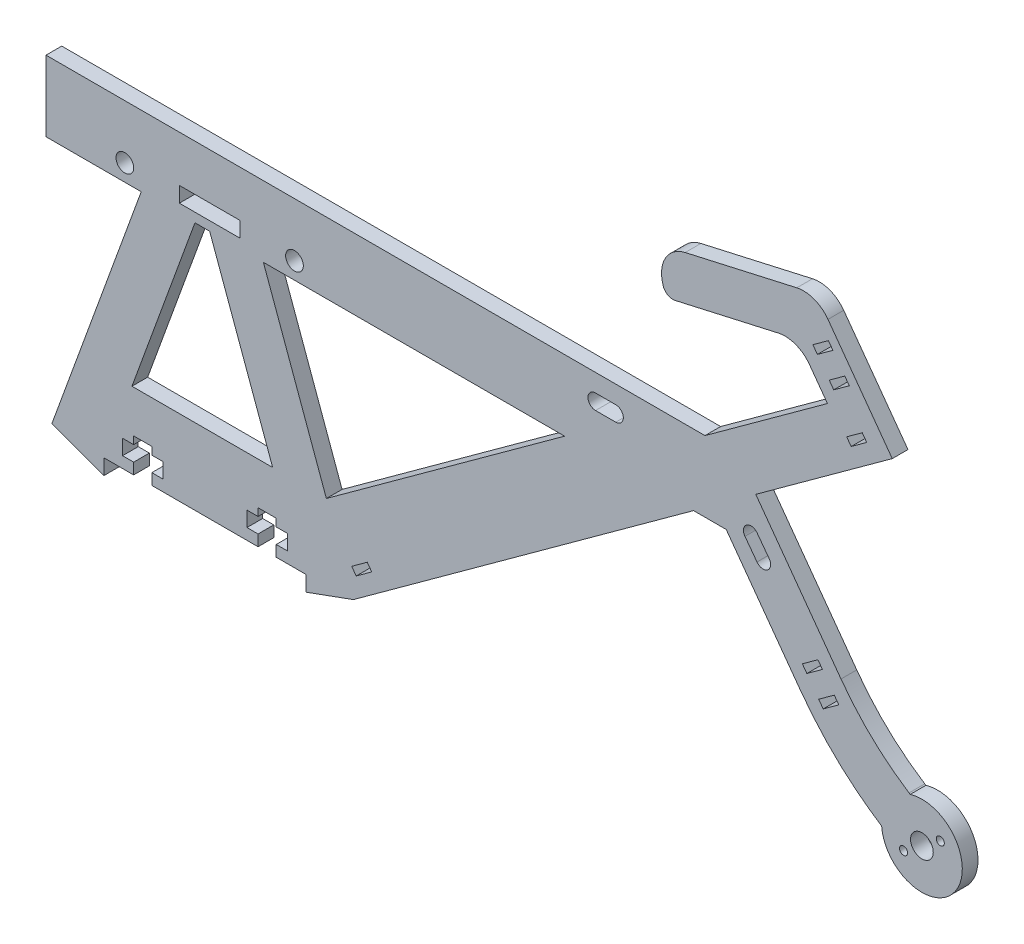
from build123d import *

# Parameters (mm, degrees)
SKETCH1_R           = 2.25
SKETCH1_R_2         = 0.8
SKETCH1_R_3         = 1.7526
BOSS_EXTRUDE1_DEPTH = 3.1115


with BuildPart() as part:
    # Sketch1 → Boss-Extrude1 (new body)
    with BuildSketch(Plane.XY):
        with BuildLine():
            Line((40.571674968, -45.901211355), (107.95698504, 3.057082175))
            Line((107.95698504, 3.057082175), (114.431306158, 3.057082175))
            Line((114.431306158, 3.057082175), (129.0733448, -17.095955091))
            add(Edge.make_bspline(
                [(129.0733448, -17.095955091), (133.53865967, -23.241933746), (138.918061624, -28.349297229), (145.211550663, -32.41804554)],
                knots=[0.5, 0.5, 0.5, 0.5, 0.915854192, 0.915854192, 0.915854192, 0.915854192], degree=3))
            ThreePointArc((145.211550663, -32.41804554), (159.788231987, -36.343991717), (150.867180903, -24.165833426))
            Line((150.867180903, -24.165833426), (150.640762289, -24.020208846))
            add(Edge.make_bspline(
                [(137.163514743, -11.218102568), (137.631181225, -11.861790257), (138.599969423, -13.134624479), (140.611611711, -15.54248749), (143.29771775, -18.340403293), (146.787953317, -21.358895338), (149.334712498, -23.17584607), (150.640762289, -24.020208846)],
                knots=[0.5, 0.5, 0.5, 0.5, 0.551981774, 0.603963548, 0.707927096, 0.811890644, 0.915854192, 0.915854192, 0.915854192, 0.915854192], degree=3))
            Line((137.163514743, -11.218102568), (120.284653169, 12.013657342))
            Line((120.284653169, 12.013657342), (120.976190903, 12.516088915))
            Line((120.976190903, 12.516088915), (147.319477841, 31.655607203))
            Line((147.319477841, 31.655607203), (145.885321673, 33.629553824))
            Line((145.885321673, 33.629553824), (134.586350681, 49.181253217))
            ThreePointArc((134.586350681, 49.181253217), (131.845960487, 51.269897662), (128.408504904, 51.506695351))
            Line((128.408504904, 51.506695351), (106.294747249, 46.504613793))
            ThreePointArc((106.294747249, 46.504613793), (102.544365306, 43.854529448), (101.766337412, 39.328716333))
            Line((101.766337412, 39.328716333), (101.888205656, 38.789947666))
            ThreePointArc((101.888205656, 38.789947666), (102.771567105, 37.539820352), (104.280171476, 37.280477721))
            Line((104.280171476, 37.280477721), (124.755382254, 41.911923712))
            ThreePointArc((124.755382254, 41.911923712), (128.192837837, 41.675126022), (130.933228031, 39.586481577))
            Line((130.933228031, 39.586481577), (134.488040457, 34.693702023))
            Line((134.488040457, 34.693702023), (110.217530626, 17.060144455))
            Line((110.217530626, 17.060144455), (34.693822445, 17.060144455))
            Line((34.693822445, 17.060144455), (-20.306177555, 17.060144455))
            Line((-20.306177555, 17.060144455), (-20.306177555, 7.060144459))
            Line((-20.306177555, 7.060144459), (-20.306177555, 3.057082175))
            Line((-20.306177555, 3.057082175), (-1.445233082, 3.057082175))
            Line((-1.445233082, 3.057082175), (-19.142654999, -45.566184926))
            Line((-19.142654999, -45.566184926), (-8.82525124, -49.321412789))
            Line((-8.82525124, -49.321412789), (-8.82525124, -46.273412789))
            Line((-8.82525124, -46.273412789), (-2.94645984, -46.273412789))
            Line((-2.94645984, -46.273412789), (-2.94645984, -44.075412789))
            Line((-2.94645984, -44.075412789), (-5.14645984, -44.075412789))
            Line((-5.14645984, -44.075412789), (-5.14645984, -41.075412789))
            Line((-5.14645984, -41.075412789), (-2.94645984, -41.075412789))
            Line((-2.94645984, -41.075412789), (-2.94645984, -39.575412789))
            Line((-2.94645984, -39.575412789), (0.65354016, -39.575412789))
            Line((0.65354016, -39.575412789), (0.65354016, -41.075412789))
            Line((0.65354016, -41.075412789), (2.85354016, -41.075412789))
            Line((2.85354016, -41.075412789), (2.85354016, -44.075412789))
            Line((2.85354016, -44.075412789), (0.65354016, -44.075412789))
            Line((0.65354016, -44.075412789), (0.65354016, -46.273412789))
            Line((0.65354016, -46.273412789), (21.695957359, -46.273412789))
            Line((21.695957359, -46.273412789), (21.695957359, -44.075412789))
            Line((21.695957359, -44.075412789), (19.495957359, -44.075412789))
            Line((19.495957359, -44.075412789), (19.495957359, -41.075412789))
            Line((19.495957359, -41.075412789), (21.695957359, -41.075412789))
            Line((21.695957359, -41.075412789), (21.695957359, -39.575412789))
            Line((21.695957359, -39.575412789), (25.295957359, -39.575412789))
            Line((25.295957359, -39.575412789), (25.295957359, -41.075412789))
            Line((25.295957359, -41.075412789), (27.495957359, -41.075412789))
            Line((27.495957359, -41.075412789), (27.495957359, -44.075412789))
            Line((27.495957359, -44.075412789), (25.295957359, -44.075412789))
            Line((25.295957359, -44.075412789), (25.295957359, -46.273412789))
            Line((25.295957359, -46.273412789), (31.17474876, -46.273412789))
            Line((31.17474876, -46.273412789), (31.17474876, -49.321412789))
            Line((31.17474876, -49.321412789), (40.571674968, -45.901211355))
        make_face()
        with Locations((153.189271476, -31.821412789)):
            Circle(SKETCH1_R, mode=Mode.SUBTRACT)
        with Locations((156.829847951, -29.176379153)):
            Circle(SKETCH1_R_2, mode=Mode.SUBTRACT)
        with Locations((149.548695001, -34.466446424)):
            Circle(SKETCH1_R_2, mode=Mode.SUBTRACT)
        with Locations((-4.689464322, 6.397861115)):
            Circle(SKETCH1_R_3, mode=Mode.SUBTRACT)
        with Locations((28.910535678, 6.397861115)):
            Circle(SKETCH1_R_3, mode=Mode.SUBTRACT)
        Polygon((22.752313402, 3.057082175), (82.411954897, 3.057082175), (35.229290336, -31.223130213), align=None, mode=Mode.SUBTRACT)
        Polygon((24.587512611, -31.223130213), (12.110535678, 3.057082175), (9.196544643, 3.057082175), (-3.28043229, -31.223130213), align=None, mode=Mode.SUBTRACT)
        with BuildLine():
            Line((88.543835939, 13.524152696), (92.543835721, 13.522830074))
            ThreePointArc((92.543835721, 13.522830074), (94.043339655, 12.022334173), (92.542843754, 10.522830238))
            Line((92.542843754, 10.522830238), (88.542843973, 10.52415286))
            ThreePointArc((88.542843973, 10.52415286), (87.043340038, 12.024648761), (88.543835939, 13.524152696))
        make_face(mode=Mode.SUBTRACT)
        with BuildLine():
            Line((120.546853002, 5.529529102), (122.932016073, 2.318454963))
            ThreePointArc((122.932016073, 2.318454963), (122.622299423, 0.21986601), (120.523710469, 0.52958266))
            Line((120.523710469, 0.52958266), (118.138547398, 3.740656799))
            ThreePointArc((118.138547398, 3.740656799), (118.448264049, 5.839245752), (120.546853002, 5.529529102))
        make_face(mode=Mode.SUBTRACT)
        Polygon((131.942859267, -12.538994841), (130.401681893, -13.658725747), (129.514126162, -12.437110085), (132.59648091, -10.197648274), (133.484036641, -11.419263935), align=None, mode=Mode.SUBTRACT)
        Polygon((134.294000276, -15.775062818), (135.835177651, -14.655331913), (136.722733382, -15.876947574), (133.640378633, -18.116409385), (132.752822902, -16.894793724), align=None, mode=Mode.SUBTRACT)
        Polygon((138.289721592, 30.886083745), (139.177277323, 29.664468084), (142.259632072, 31.903929895), (141.372076341, 33.125545557), align=None, mode=Mode.SUBTRACT)
        Polygon((40.244952044, -40.34761098), (43.327306792, -38.108149169), (44.214862523, -39.32976483), (41.132507775, -41.569226641), align=None, mode=Mode.SUBTRACT)
        Polygon((134.024760687, 43.238257986), (132.483583313, 42.118527081), (131.596027582, 43.340142742), (134.67838233, 45.579604554), (135.565938061, 44.357988892), align=None, mode=Mode.SUBTRACT)
        Polygon((136.375901696, 40.002190009), (137.917079071, 41.121920915), (138.804634802, 39.900305253), (135.722280053, 37.660843442), (134.834724322, 38.882459103), align=None, mode=Mode.SUBTRACT)
        Polygon((6.110535678, 4.873861115), (18.110535678, 4.873861115), (18.110535678, 7.921861115), (12.110535678, 7.921861115), (6.110535678, 7.921861115), align=None, mode=Mode.SUBTRACT)
    extrude(amount=BOSS_EXTRUDE1_DEPTH)


solid = part.part
